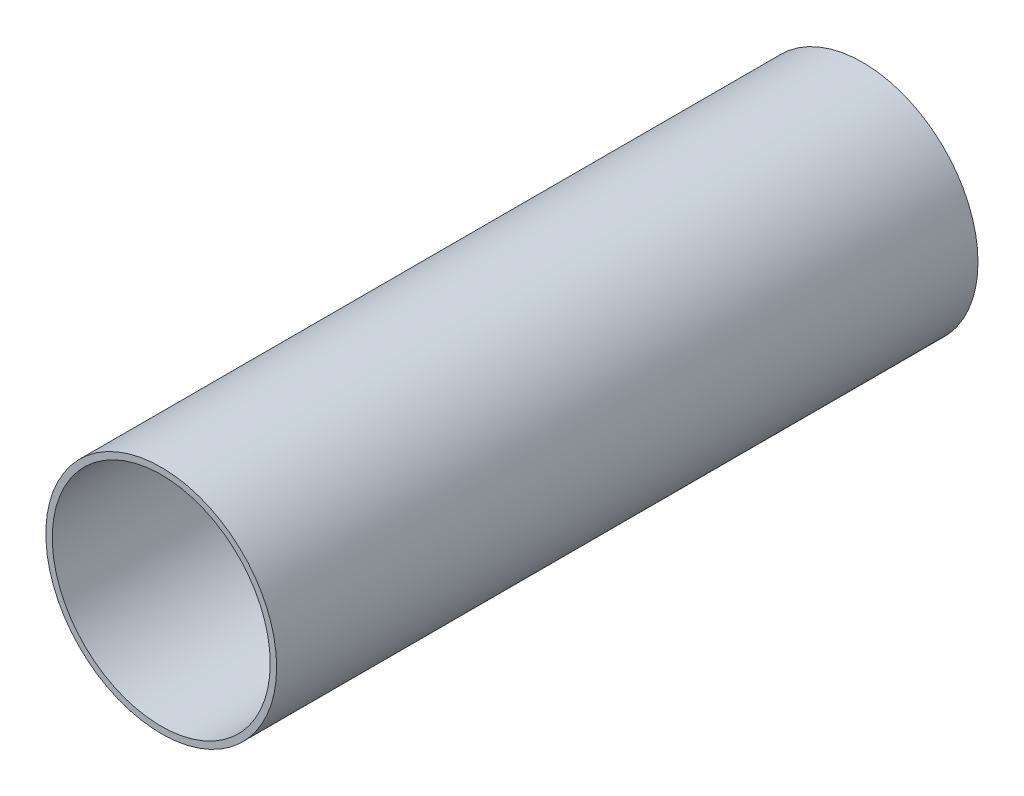
from build123d import *

# Parameters (mm, degrees)
SKETCH1_R           = 2.25
SKETCH1_R_2         = 2.125
BOSS_EXTRUDE1_DEPTH = 13.675


with BuildPart() as part:
    # Sketch1 → Boss-Extrude1 (new body)
    with BuildSketch(Plane.XY):
        Circle(SKETCH1_R)
        Circle(SKETCH1_R_2, mode=Mode.SUBTRACT)
    extrude(amount=BOSS_EXTRUDE1_DEPTH)


solid = part.part
